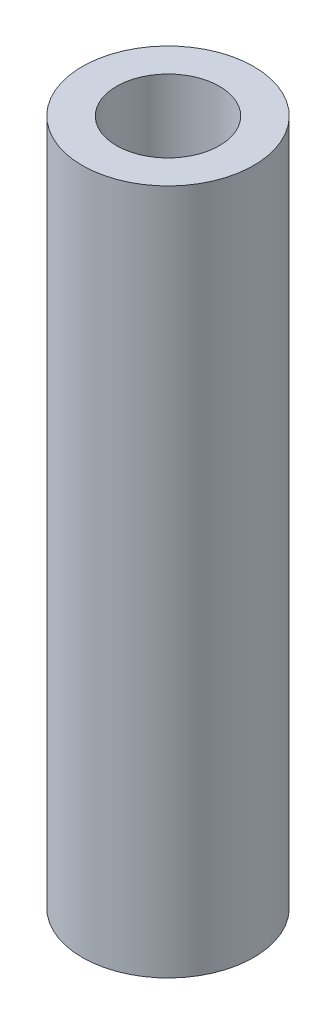
from build123d import *

# Parameters (mm, degrees)
SKETCH1_R           = 2.5
SKETCH1_R_2         = 1.5
BOSS_EXTRUDE1_DEPTH = 20


with BuildPart() as part:
    # Sketch1 → Boss-Extrude1 (new body)
    with BuildSketch(Plane(origin=(0, 0, 0), x_dir=(1, 0, 0), z_dir=(0, 1, 0))):
        Circle(SKETCH1_R)
        Circle(SKETCH1_R_2, mode=Mode.SUBTRACT)
    extrude(amount=BOSS_EXTRUDE1_DEPTH)


solid = part.part
